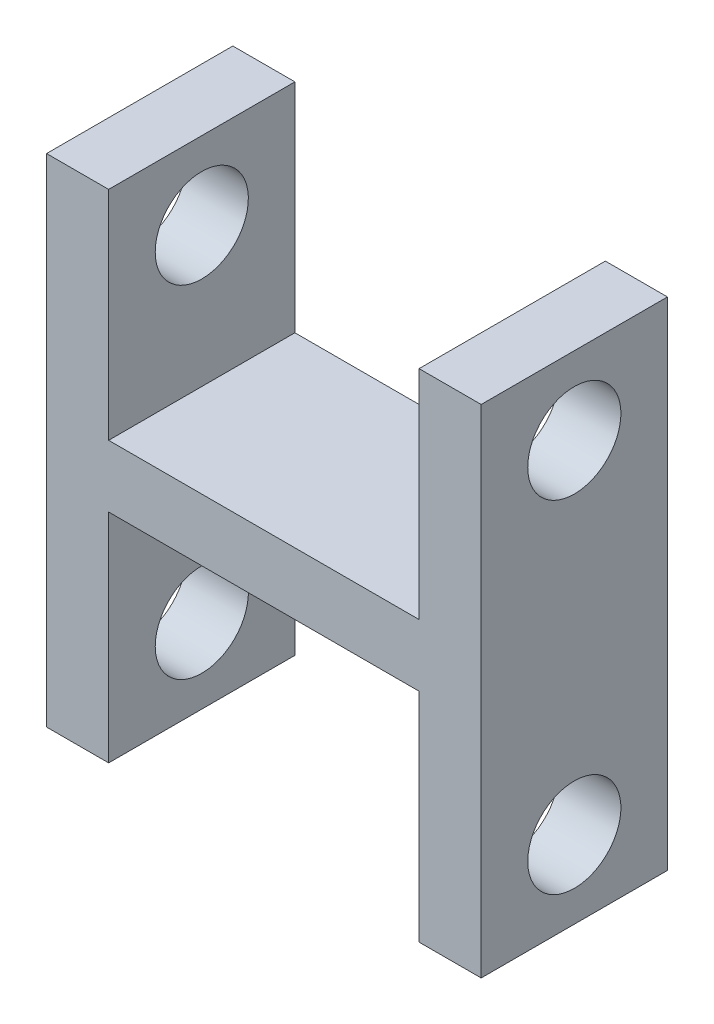
from build123d import *

# Parameters (mm, degrees)
SKETCH1_W           = 177.8
SKETCH1_H           = 203.2
BOSS_EXTRUDE2_DEPTH = 76.2
SKETCH3_W           = 127
SKETCH3_H           = 88.9
CUT_EXTRUDE1_DEPTH  = 76.2
SKETCH4_R           = 19.05
CUT_EXTRUDE3_DEPTH  = 199.898


with BuildPart() as part:
    # Sketch1 → Boss-Extrude2 (new body)
    with BuildSketch(Plane.XY):
        with Locations((88.9, 101.6)):
            Rectangle(SKETCH1_W, SKETCH1_H)
    extrude(amount=BOSS_EXTRUDE2_DEPTH)

    # Sketch3 → Cut-Extrude1 (cut)
    with BuildSketch(Plane.XY.offset(76.2)):
        with Locations((88.9, 158.75)):
            Rectangle(SKETCH3_W, SKETCH3_H)
        with Locations((88.9, 44.45)):
            Rectangle(SKETCH3_W, SKETCH3_H)
    extrude(amount=-CUT_EXTRUDE1_DEPTH, mode=Mode.SUBTRACT)

    # Sketch4 → Cut-Extrude3 (cut)
    with BuildSketch(Plane.ZY):
        with Locations((38.1, 171.45)):
            Circle(SKETCH4_R)
        with Locations((38.1, 31.75)):
            Circle(SKETCH4_R)
    extrude(amount=-CUT_EXTRUDE3_DEPTH, mode=Mode.SUBTRACT)


solid = part.part
